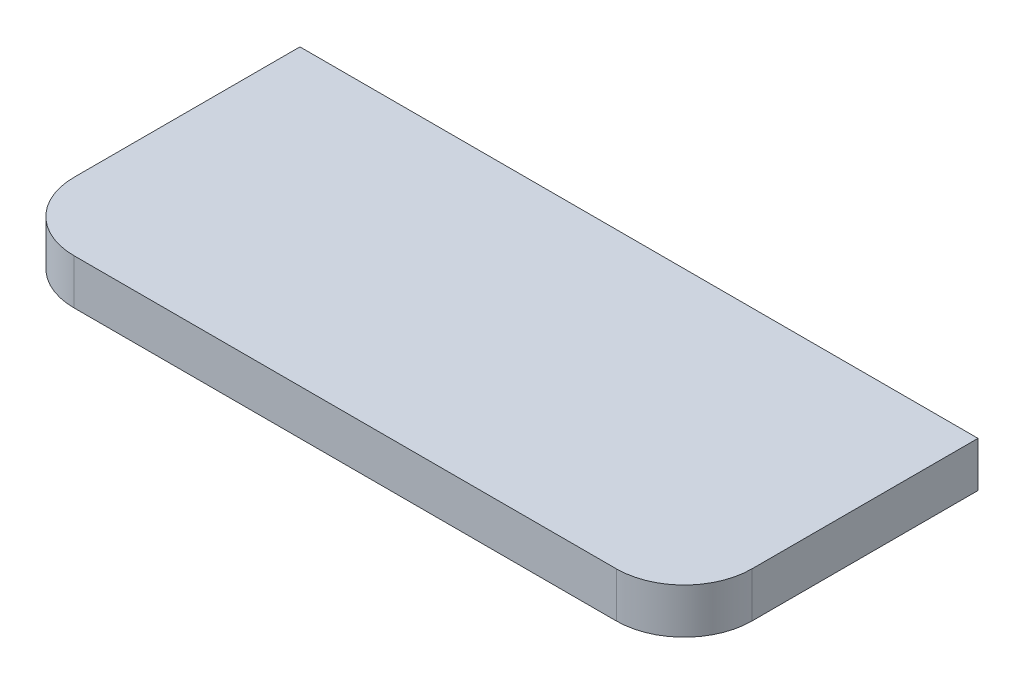
from build123d import *

# Parameters (mm, degrees)
BOSS_EXTRUDE1_DEPTH = 10


with BuildPart() as part:
    # Sketch1 → Boss-Extrude1 (new body)
    with BuildSketch(Plane(origin=(0, 0, 0), x_dir=(1, 0, 0), z_dir=(0, 1, 0))):
        with BuildLine():
            Line((-75, 0), (75, 0))
            Line((75, 0), (75, -50))
            ThreePointArc((75, -50), (70.606601718, -60.606601718), (60, -65))
            Line((60, -65), (-60, -65))
            ThreePointArc((-60, -65), (-70.606601718, -60.606601718), (-75, -50))
            Line((-75, -50), (-75, 0))
        make_face()
    extrude(amount=BOSS_EXTRUDE1_DEPTH)


solid = part.part
